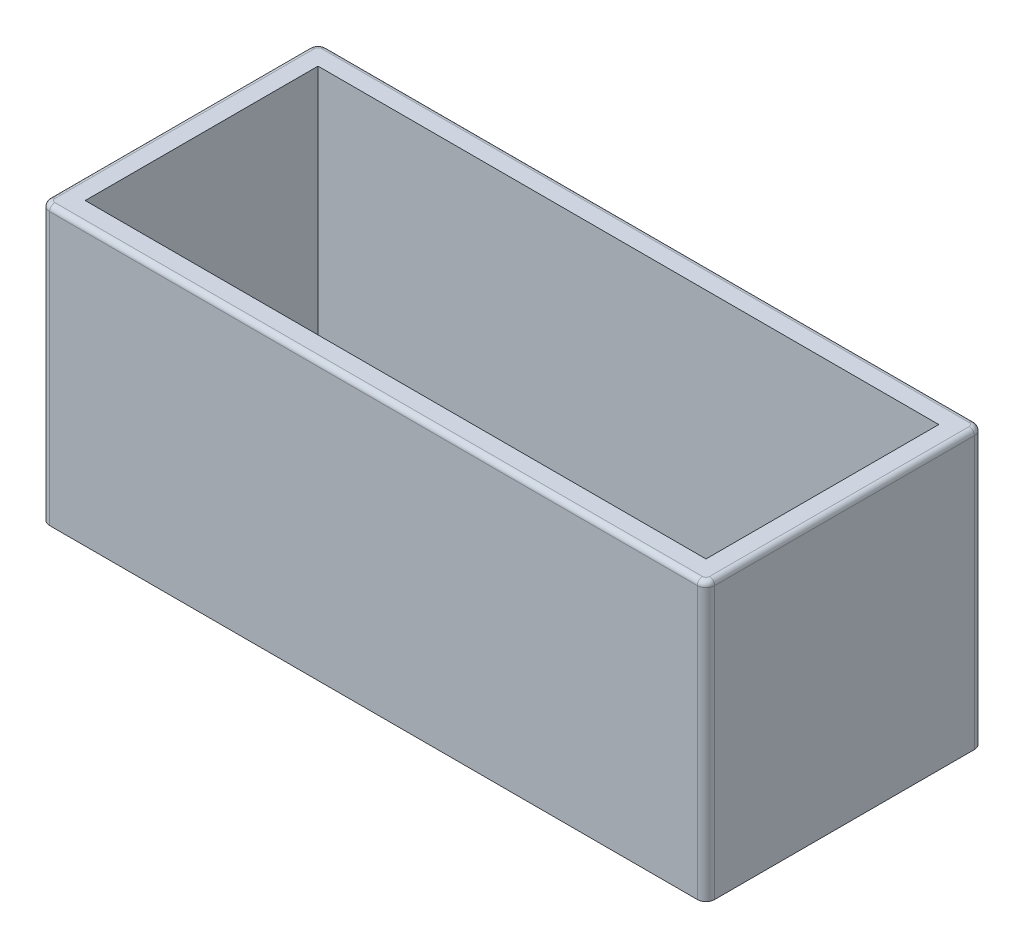
from build123d import *

# Parameters (mm, degrees)
SKETCH1_W           = 63.5
SKETCH1_H           = 63.5
BOSS_EXTRUDE1_DEPTH = 152.4
SKETCH2_W           = 142.24
SKETCH2_H           = 53.34
CUT_EXTRUDE1_DEPTH  = 58.42
FILLET1_R           = 2
FILLET2_R           = 1.2
SCALE1_SCALE        = 0.06


with BuildPart() as part:
    # Sketch1 → Boss-Extrude1 (new body)
    with BuildSketch(Plane(origin=(0, 0, 0), x_dir=(0, 0, -1), z_dir=(1, 0, 0))):
        Rectangle(SKETCH1_W, SKETCH1_H)
    extrude(amount=BOSS_EXTRUDE1_DEPTH)

    # Sketch2 → Cut-Extrude1 (cut)
    with BuildSketch(Plane(origin=(0, 31.75, 0), x_dir=(1, 0, 0), z_dir=(0, 1, 0))):
        with Locations((76.2, 0)):
            Rectangle(SKETCH2_W, SKETCH2_H)
    extrude(amount=-CUT_EXTRUDE1_DEPTH, mode=Mode.SUBTRACT)

    # Fillet1
    fillet1_edges = [part.edges().sort_by_distance(p)[0] for p in [
        (152.4, 0, 31.75),
        (152.4, 0, -31.75),
        (0, 0, 31.75),
        (0, 0, -31.75),
    ]]
    fillet(fillet1_edges, radius=FILLET1_R)

    # Fillet2
    fillet2_edges = [part.edges().sort_by_distance(p)[0] for p in [
        (152.4, 31.75, 0),
        (76.2, 31.75, 31.75),
        (0, 31.75, 0),
        (76.2, 31.75, -31.75),
        (0.585786438, 31.75, 31.164213562),
        (0.585786438, 31.75, -31.164213562),
        (151.814213562, 31.75, -31.164213562),
        (151.814213562, 31.75, 31.164213562),
    ]]
    fillet(fillet2_edges, radius=FILLET2_R)


with BuildPart() as part_1:
    # Scale1: scaled about (76.2, -6.610828931, 0)
    add(part.part.scale(SCALE1_SCALE).moved(Location((71.628, -6.214179195, 0))))


solid = part_1.part
